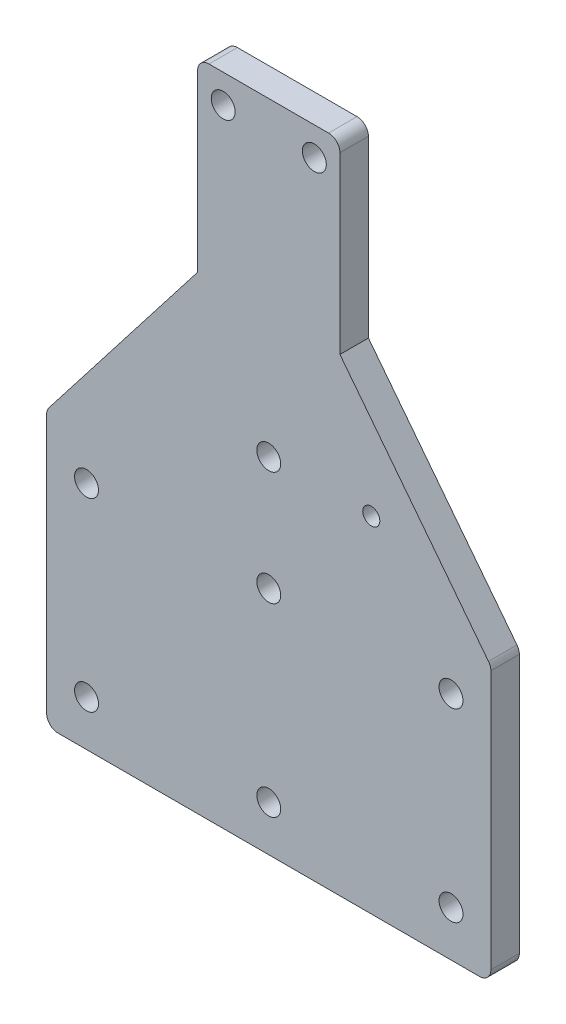
from build123d import *

# Parameters (mm, degrees)
BOSS_EXTRUDE1_DEPTH = 5
SKETCH2_R           = 2.1
SKETCH2_R_2         = 1.5
CUT_EXTRUDE1_DEPTH  = 6
SKETCH4_R           = 2.1
CUT_EXTRUDE2_DEPTH  = 6
FILLET1_R           = 2


with BuildPart() as part:
    # Sketch1 → Boss-Extrude1 (new body)
    with BuildSketch(Plane.XY):
        Polygon((-39, 100.232788632), (-12.5, 134.403841263), (-12.5, 167.075), (12.5, 167.075), (12.5, 134.403841263), (39, 100.232788632), (39, 52.075), (27.012855738, 52.075), (-27.012855738, 52.075), (-39, 52.075), align=None)
    extrude(amount=BOSS_EXTRUDE1_DEPTH)

    # Sketch2 → Cut-Extrude1 (cut, through all)
    with BuildSketch(Plane(origin=(0, 0, 0), x_dir=(-1, 0, 0), z_dir=(0, 0, -1))):
        with Locations((-32, 92.575)):
            Circle(SKETCH2_R)
        with Locations((32, 92.575)):
            Circle(SKETCH2_R)
        with Locations((8, 162.075)):
            Circle(SKETCH2_R)
        with Locations((-8, 162.075)):
            Circle(SKETCH2_R)
        with Locations((-18, 112.575)):
            Circle(SKETCH2_R_2)
    extrude(amount=-CUT_EXTRUDE1_DEPTH, mode=Mode.SUBTRACT)

    # Sketch4 → Cut-Extrude2 (cut, through all)
    with BuildSketch(Plane(origin=(0, 0, 0), x_dir=(-1, 0, 0), z_dir=(0, 0, -1))):
        with Locations((-32, 60.075)):
            Circle(SKETCH4_R)
        with Locations((32, 60.075)):
            Circle(SKETCH4_R)
        with Locations((0, 60.075)):
            Circle(SKETCH4_R)
        with Locations((0, 112.575)):
            Circle(SKETCH4_R)
        with Locations((0, 92.575)):
            Circle(SKETCH4_R)
    extrude(amount=-CUT_EXTRUDE2_DEPTH, mode=Mode.SUBTRACT)

    # Fillet1
    fillet1_edges = [part.edges().sort_by_distance(p)[0] for p in [
        (-39, 100.232788632, 2.5),
        (-12.5, 167.075, 2.5),
        (12.5, 167.075, 2.5),
        (39, 100.232788632, 2.5),
        (39, 52.075, 2.5),
        (-39, 52.075, 2.5),
    ]]
    fillet(fillet1_edges, radius=FILLET1_R)


solid = part.part
